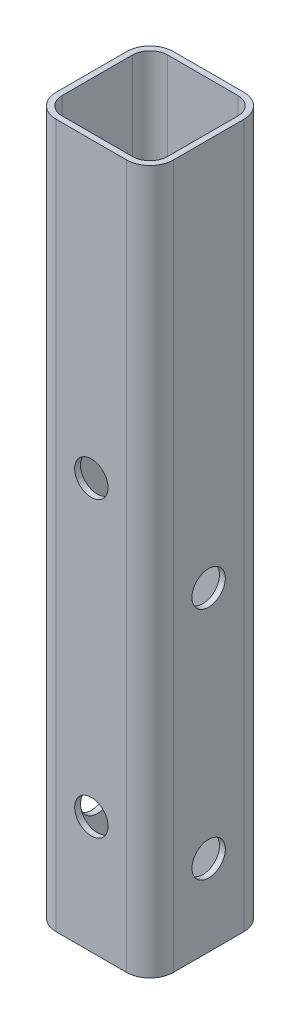
from build123d import *

# Parameters (mm, degrees)
BOSS_EXTRUDE1_DEPTH = 152.4
SKETCH2_R           = 3.6195
CUT_EXTRUDE1_DEPTH  = 26.4
SKETCH3_R           = 3.6195
CUT_EXTRUDE2_DEPTH  = 26.4


with BuildPart() as part:
    # Sketch1 → Boss-Extrude1 (new body)
    with BuildSketch(Plane(origin=(0, 0, 0), x_dir=(1, 0, 0), z_dir=(0, 1, 0))):
        with BuildLine():
            Line((-7.62, 12.7), (7.62, 12.7))
            ThreePointArc((7.62, 12.7), (11.212102448, 11.212102448), (12.7, 7.62))
            Line((12.7, 7.62), (12.7, -7.62))
            ThreePointArc((12.7, -7.62), (11.212102448, -11.212102448), (7.62, -12.7))
            Line((7.62, -12.7), (-7.62, -12.7))
            ThreePointArc((-7.62, -12.7), (-11.212102448, -11.212102448), (-12.7, -7.62))
            Line((-12.7, -7.62), (-12.7, 7.62))
            ThreePointArc((-12.7, 7.62), (-11.212102448, 11.212102448), (-7.62, 12.7))
        make_face()
        with BuildLine():
            Line((-7.62, 11.43), (7.62, 11.43))
            ThreePointArc((7.62, 11.43), (10.314076836, 10.314076836), (11.43, 7.62))
            Line((11.43, 7.62), (11.43, -7.62))
            ThreePointArc((11.43, -7.62), (10.314076836, -10.314076836), (7.62, -11.43))
            Line((7.62, -11.43), (-7.62, -11.43))
            ThreePointArc((-7.62, -11.43), (-10.314076836, -10.314076836), (-11.43, -7.62))
            Line((-11.43, -7.62), (-11.43, 7.62))
            ThreePointArc((-11.43, 7.62), (-10.314076836, 10.314076836), (-7.62, 11.43))
        make_face(mode=Mode.SUBTRACT)
    extrude(amount=BOSS_EXTRUDE1_DEPTH)

    # Sketch2 → Cut-Extrude1 (cut, through all)
    with BuildSketch(Plane.XY.offset(12.7)):
        with Locations((0, 88.9)):
            Circle(SKETCH2_R)
        with Locations((0, 25.4)):
            Circle(SKETCH2_R)
    extrude(amount=-CUT_EXTRUDE1_DEPTH, mode=Mode.SUBTRACT)

    # Sketch3 → Cut-Extrude2 (cut, through all)
    with BuildSketch(Plane.ZY.offset(12.7)):
        with Locations((0, 68.326)):
            Circle(SKETCH3_R)
        with Locations((0, 17.526)):
            Circle(SKETCH3_R)
    extrude(amount=-CUT_EXTRUDE2_DEPTH, mode=Mode.SUBTRACT)


solid = part.part
